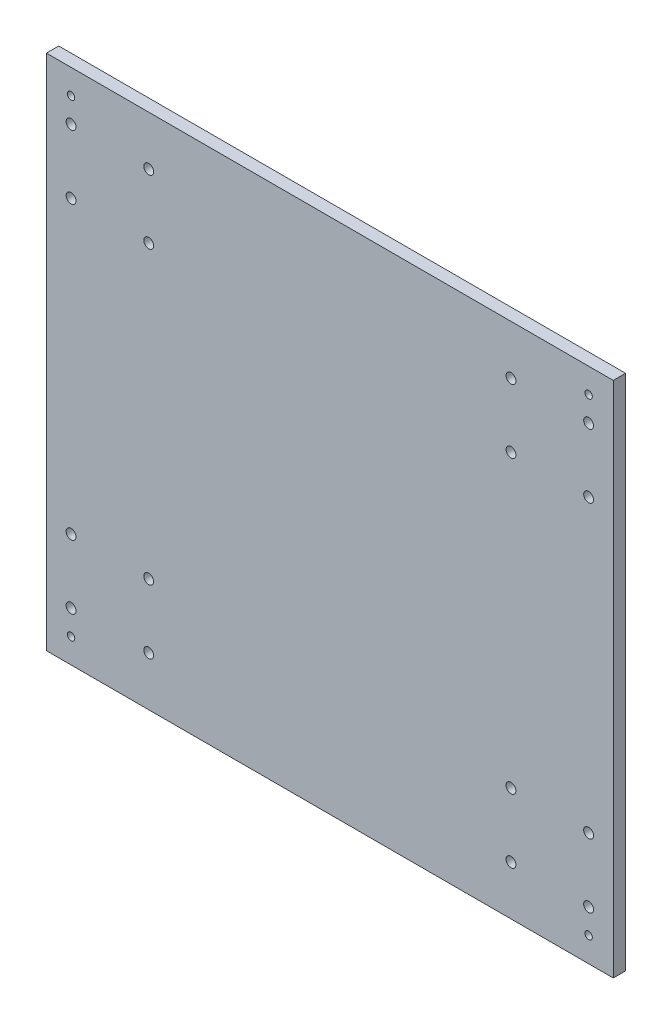
from build123d import *

# Parameters (mm, degrees)
IZIM1_W                     = 230
IZIM1_H                     = 210
IZIM1_R                     = 2
IZIM1_R_2                   = 1.5
Y_KSEKLIK_EKSTR_ZYON1_DEPTH = 5


with BuildPart() as part:
    # Çizim1 → Yükseklik-Ekstrüzyon1 (new body)
    with BuildSketch(Plane.XY):
        Rectangle(IZIM1_W, IZIM1_H)
        with Locations((-105, 85)):
            Circle(IZIM1_R, mode=Mode.SUBTRACT)
        with Locations((-73.5, 85)):
            Circle(IZIM1_R, mode=Mode.SUBTRACT)
        with Locations((-105, 59)):
            Circle(IZIM1_R, mode=Mode.SUBTRACT)
        with Locations((-73.5, 59)):
            Circle(IZIM1_R, mode=Mode.SUBTRACT)
        with Locations((-105, 95)):
            Circle(IZIM1_R_2, mode=Mode.SUBTRACT)
        with Locations((-105, -59)):
            Circle(IZIM1_R, mode=Mode.SUBTRACT)
        with Locations((-105, -85)):
            Circle(IZIM1_R, mode=Mode.SUBTRACT)
        with Locations((-105, -95)):
            Circle(IZIM1_R_2, mode=Mode.SUBTRACT)
        with Locations((-73.5, -59)):
            Circle(IZIM1_R, mode=Mode.SUBTRACT)
        with Locations((-73.5, -85)):
            Circle(IZIM1_R, mode=Mode.SUBTRACT)
        with Locations((73.5, -85)):
            Circle(IZIM1_R, mode=Mode.SUBTRACT)
        with Locations((73.5, -59)):
            Circle(IZIM1_R, mode=Mode.SUBTRACT)
        with Locations((105, -95)):
            Circle(IZIM1_R_2, mode=Mode.SUBTRACT)
        with Locations((105, -85)):
            Circle(IZIM1_R, mode=Mode.SUBTRACT)
        with Locations((105, -59)):
            Circle(IZIM1_R, mode=Mode.SUBTRACT)
        with Locations((105, 95)):
            Circle(IZIM1_R_2, mode=Mode.SUBTRACT)
        with Locations((73.5, 59)):
            Circle(IZIM1_R, mode=Mode.SUBTRACT)
        with Locations((105, 59)):
            Circle(IZIM1_R, mode=Mode.SUBTRACT)
        with Locations((73.5, 85)):
            Circle(IZIM1_R, mode=Mode.SUBTRACT)
        with Locations((105, 85)):
            Circle(IZIM1_R, mode=Mode.SUBTRACT)
    extrude(amount=Y_KSEKLIK_EKSTR_ZYON1_DEPTH)


solid = part.part
